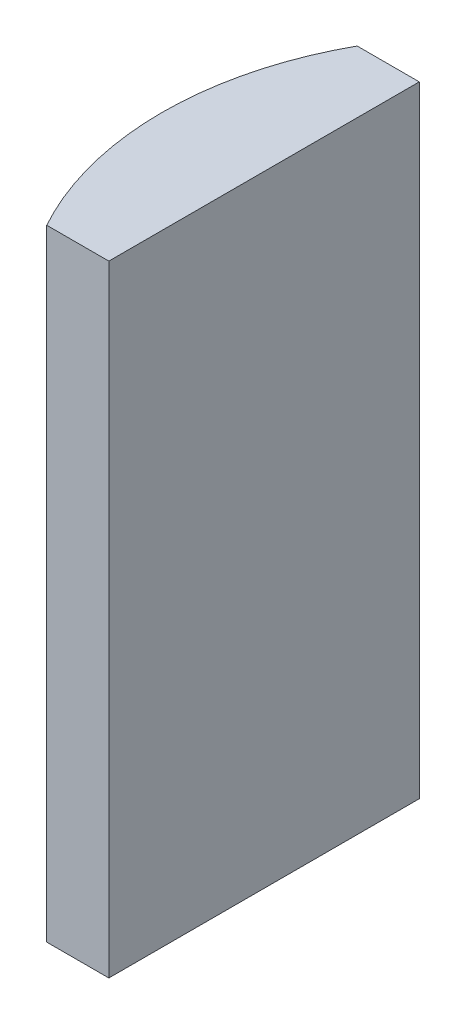
from build123d import *

# Parameters (mm, degrees)
EXTRUDE_1_DEPTH = 20


with BuildPart() as part:
    # 草图1 → 凸台-拉伸1 (new body)
    with BuildSketch(Plane(origin=(0, 0, 0), x_dir=(1, 0, 0), z_dir=(0, 1, 0))):
        with BuildLine():
            Line((-4.695519393, 5), (-2.694795665, 5))
            Line((-2.694795665, 5), (-2.694795665, -5))
            Line((-2.694795665, -5), (-4.695519393, -5))
            ThreePointArc((-4.695519393, -5), (-5.984795665, 0), (-4.695519393, 5))
        make_face()
    extrude(amount=EXTRUDE_1_DEPTH)


solid = part.part
